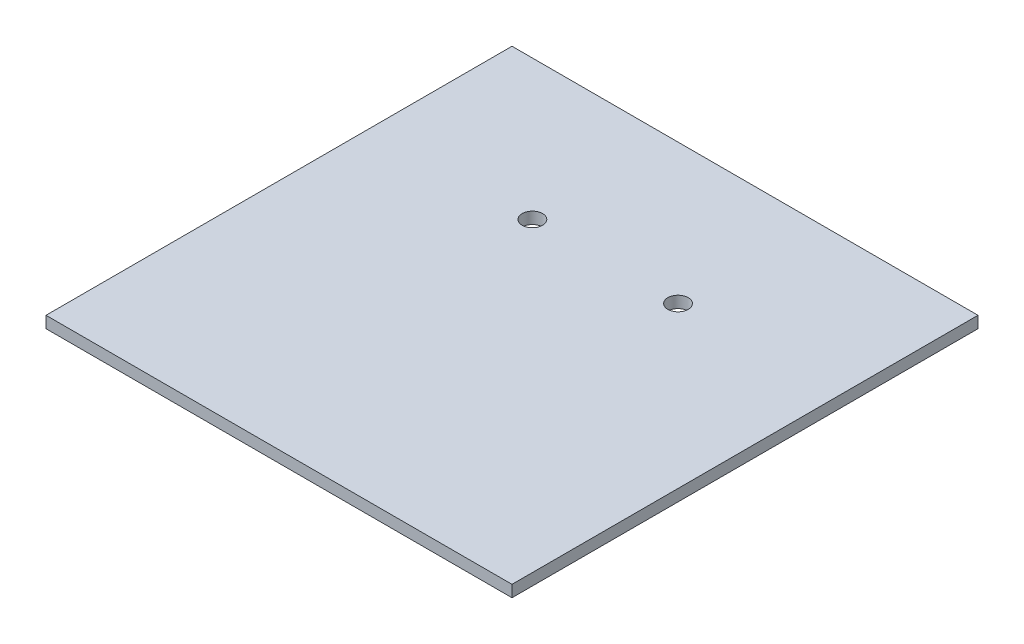
from build123d import *

# Parameters (mm, degrees)
ESQUISSE1_W             = 80
ESQUISSE1_H             = 80
BOSS_EXTRU_1_DEPTH      = 2
ENL_V_MAT_EXTRU_1_REACH = 4
ESQUISSE2_R             = 1.75


with BuildPart() as part:
    # Esquisse1 → Boss.-Extru.1 (new body)
    with BuildSketch(Plane(origin=(0, 0, 0), x_dir=(1, 0, 0), z_dir=(0, 1, 0))):
        with Locations((40, 40)):
            Rectangle(ESQUISSE1_W, ESQUISSE1_H)
    extrude(amount=BOSS_EXTRU_1_DEPTH)

    # Esquisse2 → Enlèv. mat.-Extru.1 (cut, up to next)
    with BuildSketch(Plane(origin=(0, 2, 0), x_dir=(1, 0, 0), z_dir=(0, 1, 0)), mode=Mode.PRIVATE) as enl_v_mat_extru_1_sk1:
        with Locations((27.5, 56)):
            Circle(ESQUISSE2_R)
    enl_v_mat_extru_1_tool1 = extrude(enl_v_mat_extru_1_sk1.sketch, amount=-ENL_V_MAT_EXTRU_1_REACH, mode=Mode.PRIVATE) & part.part
    add(enl_v_mat_extru_1_tool1.solids().sort_by_distance((27.5, 2, -56))[0], mode=Mode.SUBTRACT)
    # Esquisse2 → Enlèv. mat.-Extru.1 (cut, up to next)
    with BuildSketch(Plane(origin=(0, 2, 0), x_dir=(1, 0, 0), z_dir=(0, 1, 0)), mode=Mode.PRIVATE) as enl_v_mat_extru_1_sk2:
        with Locations((52.5, 56)):
            Circle(ESQUISSE2_R)
    enl_v_mat_extru_1_tool2 = extrude(enl_v_mat_extru_1_sk2.sketch, amount=-ENL_V_MAT_EXTRU_1_REACH, mode=Mode.PRIVATE) & part.part
    add(enl_v_mat_extru_1_tool2.solids().sort_by_distance((52.5, 2, -56))[0], mode=Mode.SUBTRACT)


solid = part.part
